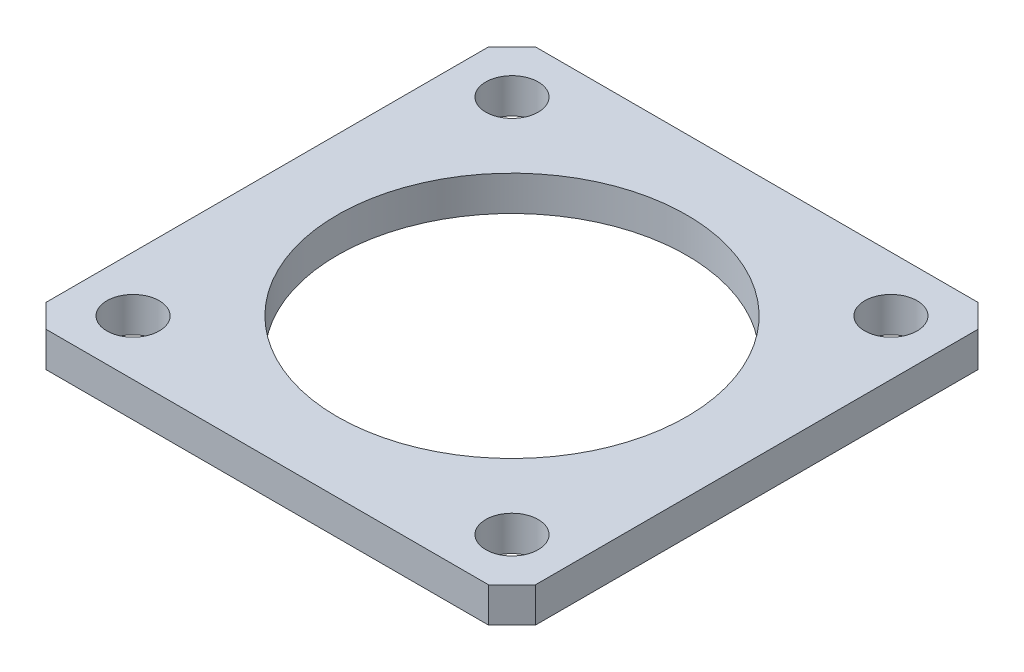
from build123d import *

# Parameters (mm, degrees)
SKETCH1_R           = 2.25
SKETCH1_R_2         = 15
BOSS_EXTRUDE1_DEPTH = 3


with BuildPart() as part:
    # Sketch1 → Boss-Extrude1 (new body)
    with BuildSketch(Plane(origin=(0, 0, 0), x_dir=(1, 0, 0), z_dir=(0, 1, 0))):
        Polygon((19, 21), (21, 19), (21, -19), (19, -21), (-19, -21), (-21, -19), (-21, 19), (-19, 21), align=None)
        with Locations((-16.263455967, 16.263455967)):
            Circle(SKETCH1_R, mode=Mode.SUBTRACT)
        with Locations((16.263455967, 16.263455967)):
            Circle(SKETCH1_R, mode=Mode.SUBTRACT)
        with Locations((16.263455967, -16.263455967)):
            Circle(SKETCH1_R, mode=Mode.SUBTRACT)
        with Locations((-16.263455967, -16.263455967)):
            Circle(SKETCH1_R, mode=Mode.SUBTRACT)
        Circle(SKETCH1_R_2, mode=Mode.SUBTRACT)
    extrude(amount=BOSS_EXTRUDE1_DEPTH)


solid = part.part
